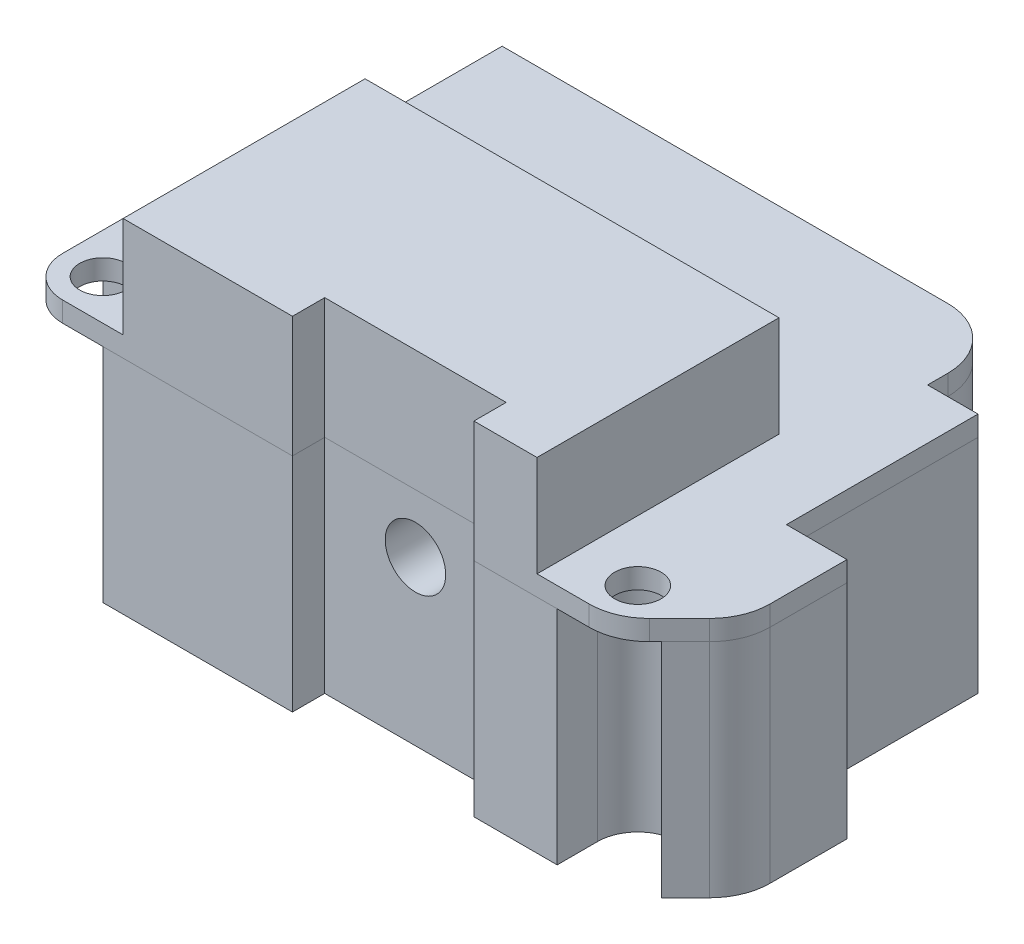
from build123d import *

# Parameters (mm, degrees)
SKETCH_1_R          = 1.15
EXTRUDE_1_DEPTH     = 1
EXTRUDE_2_DEPTH     = 11
CUT_EXTRUDE_1_DEPTH = 11
SKETCH_5_W          = 20.529289322
SKETCH_5_H          = 12
EXTRUDE_3_DEPTH     = 5
SKETCH_6_W          = 9
SKETCH_6_H          = 3.2
CUT_EXTRUDE_2_DEPTH = 18
SKETCH_7_R          = 1.5
CUT_EXTRUDE_3_DEPTH = 4


with BuildPart() as part:
    # 草图1 → 凸台-拉伸1 (new body)
    with BuildSketch(Plane(origin=(0, 0, 0), x_dir=(1, 0, 0), z_dir=(0, 1, 0))):
        with BuildLine():
            Line((-14.3, 8.9), (-14.3, 12.9))
            Line((-14.3, 12.9), (7.8, 12.9))
            ThreePointArc((7.8, 12.9), (9.921320344, 12.021320344), (10.8, 9.9))
            Line((10.8, 9.9), (10.8, 8.9))
            Line((10.8, 8.9), (13.3, 8.9))
            Line((13.3, 8.9), (13.3, -0.6))
            Line((13.3, -0.6), (16.3, -0.6))
            Line((16.3, -0.6), (16.3, -4.41507576))
            ThreePointArc((16.3, -4.41507576), (16.071638598, -5.563126057), (15.421320344, -6.536396103))
            Line((15.421320344, -6.536396103), (13.936396103, -8.021320344))
            ThreePointArc((13.936396103, -8.021320344), (12.963126057, -8.671638598), (11.81507576, -8.9))
            Line((11.81507576, -8.9), (-14.3, -8.9))
            ThreePointArc((-14.3, -8.9), (-15.714213562, -8.314213562), (-16.3, -6.9))
            Line((-16.3, -6.9), (-16.3, 1.4))
            Line((-16.3, 1.4), (-14.3, 1.4))
            Line((-14.3, 1.4), (-14.3, 8.9))
        make_face()
        with Locations((-14.3, -6.9)):
            Circle(SKETCH_1_R, mode=Mode.SUBTRACT)
        with Locations((12.229289322, -6.9)):
            Circle(SKETCH_1_R, mode=Mode.SUBTRACT)
    extrude(amount=EXTRUDE_1_DEPTH)

    # 草图5 → 凸台-拉伸3 (add)
    with BuildSketch(Plane(origin=(0, 1, 0), x_dir=(1, 0, 0), z_dir=(0, 1, 0))):
        with Locations((-1.035355339, -2.9)):
            Rectangle(SKETCH_5_W, SKETCH_5_H)
    extrude(amount=EXTRUDE_3_DEPTH)


with BuildPart() as body_2:
    # 草图2 → 凸台-拉伸2 (new body)
    with BuildSketch(Plane(origin=(0, 0, 0), x_dir=(1, 0, 0), z_dir=(0, 1, 0))):
        with BuildLine():
            Line((-14.3, -8.9), (11.81507576, -8.9))
            ThreePointArc((11.81507576, -8.9), (12.963126057, -8.671638598), (13.936396103, -8.021320344))
            Line((13.936396103, -8.021320344), (15.421320344, -6.536396103))
            ThreePointArc((15.421320344, -6.536396103), (16.071638598, -5.563126057), (16.3, -4.41507576))
            Line((16.3, -4.41507576), (16.3, -0.6))
            Line((16.3, -0.6), (13.3, -0.6))
            Line((13.3, -0.6), (13.3, 8.9))
            Line((13.3, 8.9), (10.8, 8.9))
            Line((10.8, 8.9), (10.8, 9.9))
            ThreePointArc((10.8, 9.9), (9.921320344, 12.021320344), (7.8, 12.9))
            Line((7.8, 12.9), (-14.3, 12.9))
            Line((-14.3, 12.9), (-14.3, 1.4))
            Line((-14.3, 1.4), (-16.3, 1.4))
            Line((-16.3, 1.4), (-16.3, -6.9))
            ThreePointArc((-16.3, -6.9), (-15.714213562, -8.314213562), (-14.3, -8.9))
        make_face()
    extrude(amount=-EXTRUDE_2_DEPTH)

    # 草图4 → 切除-拉伸1 (cut)
    with BuildSketch(Plane.XZ.offset(11)):
        with BuildLine():
            Line((-12.3, 6.9), (-12.3, 8.9))
            Line((-12.3, 8.9), (-14.3, 8.9))
            ThreePointArc((-14.3, 8.9), (-15.714213562, 8.314213562), (-16.3, 6.9))
            Line((-16.3, 6.9), (-16.3, 4.9))
            Line((-16.3, 4.9), (-14.3, 4.9))
            ThreePointArc((-14.3, 4.9), (-12.885786438, 5.485786438), (-12.3, 6.9))
        make_face()
        with BuildLine():
            Line((10.229289322, 8.9), (10.229289322, 6.9))
            ThreePointArc((10.229289322, 6.9), (12.229289322, 4.9), (14.229289322, 6.9))
            Line((14.229289322, 6.9), (14.229289322, 7.728427125))
            Line((14.229289322, 7.728427125), (13.936396103, 8.021320344))
            ThreePointArc((13.936396103, 8.021320344), (12.963126057, 8.671638598), (11.81507576, 8.9))
            Line((11.81507576, 8.9), (10.229289322, 8.9))
        make_face()
    extrude(amount=-CUT_EXTRUDE_1_DEPTH, mode=Mode.SUBTRACT)


with BuildPart() as cut_extrude_2_tool:
    # 草图6 → 切除-拉伸2 (new body, through all)
    with BuildSketch(Plane.XZ.offset(11)):
        with Locations((1.6, 8.9)):
            Rectangle(SKETCH_6_W, SKETCH_6_H)
    extrude(amount=-CUT_EXTRUDE_2_DEPTH)


with BuildPart() as part_1:
    add(part.part)

    # 切除-拉伸2: cut by cut_extrude_2_tool
    add(cut_extrude_2_tool.part, mode=Mode.SUBTRACT)


with BuildPart() as body_2_1:
    add(body_2.part)

    # 切除-拉伸2: cut by cut_extrude_2_tool
    add(cut_extrude_2_tool.part, mode=Mode.SUBTRACT)

    # 草图7 → 切除-拉伸3 (cut)
    with BuildSketch(Plane.XY.offset(7.3)):
        with Locations((1.6, -2.9)):
            Circle(SKETCH_7_R)
    extrude(amount=-CUT_EXTRUDE_3_DEPTH, mode=Mode.SUBTRACT)


solid = Compound([part_1.part, body_2_1.part])
